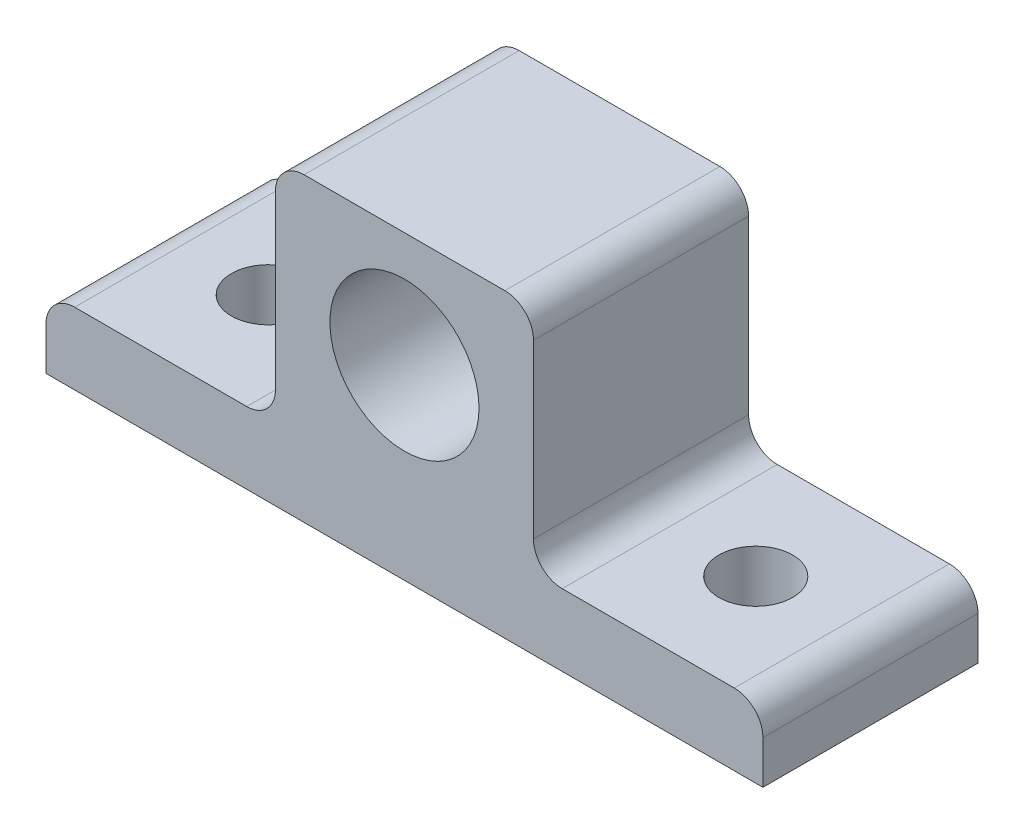
from build123d import *

# Parameters (mm, degrees)
SKETCH1_W           = 17.78
SKETCH1_H           = 19.05
SKETCH1_R           = 3.2639
SKETCH1_W_2         = 27.94
BOSS_EXTRUDE3_DEPTH = 6.35
SKETCH3_W           = 22.86
SKETCH3_H           = 19.05
BOSS_EXTRUDE4_DEPTH = 20.32
SKETCH6_R           = 6.604
CUT_EXTRUDE1_DEPTH  = 20.32
FILLET5_R           = 2.54


with BuildPart() as part:
    # Sketch1 → Boss-Extrude3 (new body)
    with BuildSketch(Plane(origin=(0, 0, 0), x_dir=(1, 0, 0), z_dir=(0, 1, 0))):
        with Locations((-26.491045528, -6.411090754)):
            Rectangle(SKETCH1_W, SKETCH1_H)
        with Locations((-25.221045528, -6.411090754)):
            Circle(SKETCH1_R, mode=Mode.SUBTRACT)
        with Locations((-3.631045528, -6.411090754)):
            Rectangle(SKETCH1_W_2, SKETCH1_H)
        with Locations((19.228954472, -6.411090754)):
            Rectangle(SKETCH1_W, SKETCH1_H)
        with Locations((17.958954472, -6.411090754)):
            Circle(SKETCH1_R, mode=Mode.SUBTRACT)
    extrude(amount=BOSS_EXTRUDE3_DEPTH)

    # Sketch3 → Boss-Extrude4 (add)
    with BuildSketch(Plane(origin=(0, 6.35, 0), x_dir=(1, 0, 0), z_dir=(0, 1, 0))):
        with Locations((-3.631045528, -6.411090754)):
            Rectangle(SKETCH3_W, SKETCH3_H)
    extrude(amount=BOSS_EXTRUDE4_DEPTH)

    # Sketch6 → Cut-Extrude1 (cut)
    with BuildSketch(Plane.XY.offset(15.936090754)):
        with Locations((-3.631045528, 16.51)):
            Circle(SKETCH6_R)
    extrude(amount=-CUT_EXTRUDE1_DEPTH, mode=Mode.SUBTRACT)

    # Fillet5
    fillet5_edges = [part.edges().sort_by_distance(p)[0] for p in [
        (-15.061045528, 6.35, 6.411090754),
        (-35.381045528, 6.35, 6.411090754),
        (28.118954472, 6.35, 6.411090754),
        (7.798954472, 26.67, 6.411090754),
        (-15.061045528, 26.67, 6.411090754),
        (7.798954472, 6.35, 6.411090754),
    ]]
    fillet(fillet5_edges, radius=FILLET5_R)


solid = part.part
